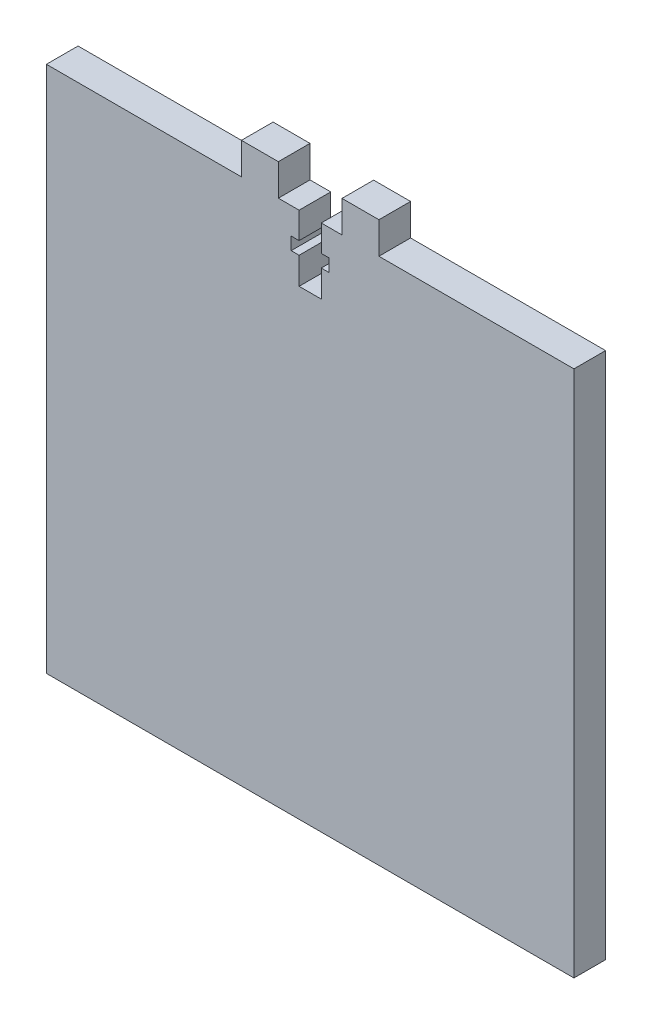
from build123d import *

# Parameters (mm, degrees)
SKETCH_1_W          = 100
SKETCH_1_H          = 100
EXTRUDE_1_DEPTH     = 6
SKETCH_2_W          = 7
SKETCH_2_H          = 6
EXTRUDE_2_DEPTH     = 6
CUT_EXTRUDE_1_DEPTH = 7


with BuildPart() as part:
    # Эскиз1 → Бобышка-Вытянуть1 (new body)
    with BuildSketch(Plane.XY):
        Rectangle(SKETCH_1_W, SKETCH_1_H)
    extrude(amount=EXTRUDE_1_DEPTH)

    # Эскиз2 → Бобышка-Вытянуть2 (add)
    with BuildSketch(Plane.XY.offset(6)):
        with Locations((-9.531849908, 53)):
            Rectangle(SKETCH_2_W, SKETCH_2_H)
        with Locations((9.531849908, 53)):
            Rectangle(SKETCH_2_W, SKETCH_2_H)
    extrude(amount=-EXTRUDE_2_DEPTH)

    # Эскиз3 → Вырез-Вытянуть1 (cut, through all)
    with BuildSketch(Plane.XY.offset(6)):
        Polygon((-2.1, 45), (-3.6, 45), (-3.6, 42.6), (-2.1, 42.6), (-2.1, 37.5), (2.1, 37.5), (2.1, 42.6), (3.6, 42.6), (3.6, 45), (2.1, 45), (2.1, 50), (-2.1, 50), align=None)
    extrude(amount=-CUT_EXTRUDE_1_DEPTH, mode=Mode.SUBTRACT)


solid = part.part
